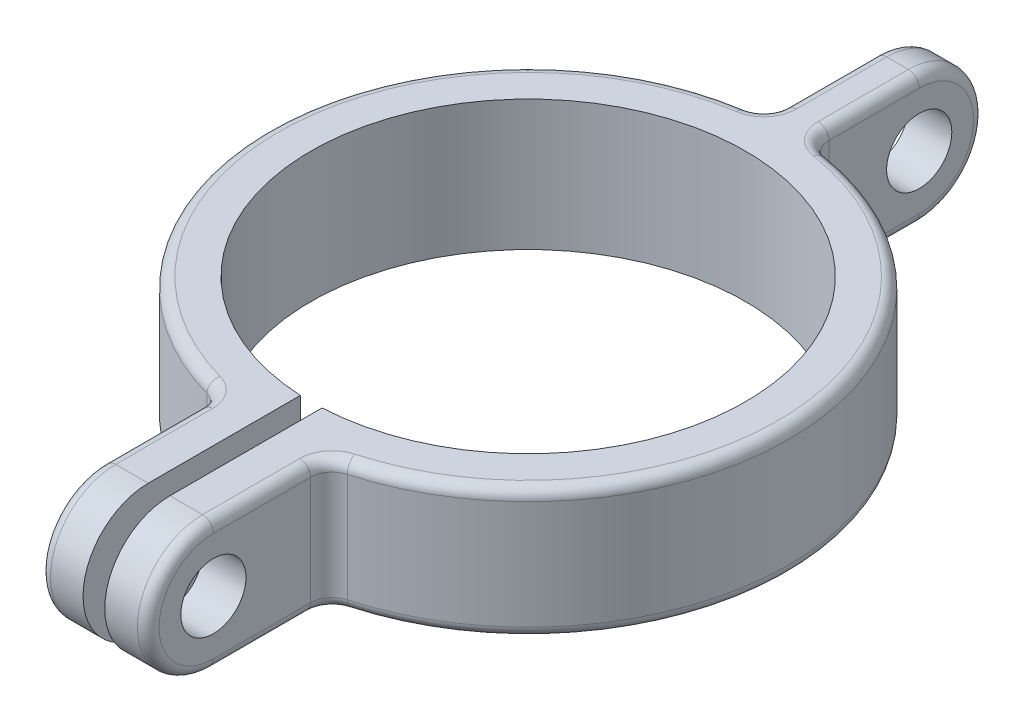
from build123d import *

# Parameters (mm, degrees)
SKETCH1_R          = 38.1
SKETCH1_R_2        = 31.75
EXTRUDE1_DEPTH     = 19.05
SKETCH2_W          = 3.175
SKETCH2_H          = 40.64
CUT_EXTRUDE1_DEPTH = 20.05
EXTRUDE2_DEPTH     = 6.35
SKETCH6_R          = 4.7625
CUT_EXTRUDE3_DEPTH = 47.0375
EXTRUDE4_DEPTH     = 3.175
FILLET4_R          = 3.175
SKETCH10_R         = 4.7625
CUT_EXTRUDE6_DEPTH = 42.275
FILLET5_R          = 1.5875


with BuildPart() as part:
    # Sketch1 → Extrude1 (new body)
    with BuildSketch(Plane(origin=(0, 0, 0), x_dir=(1, 0, 0), z_dir=(0, 1, 0))):
        Circle(SKETCH1_R)
        Circle(SKETCH1_R_2, mode=Mode.SUBTRACT)
    extrude(amount=EXTRUDE1_DEPTH)

    # Sketch2 → Cut-Extrude1 (cut, through all)
    with BuildSketch(Plane(origin=(0, 19.05, 0), x_dir=(-1, 0, 0), z_dir=(0, 1, 0))):
        with Locations((0, 20.32)):
            Rectangle(SKETCH2_W, SKETCH2_H)
    extrude(amount=-CUT_EXTRUDE1_DEPTH, mode=Mode.SUBTRACT)

    # Sketch3 → Extrude2 (add)
    with BuildSketch(Plane.ZY.offset(-1.5875)):
        with BuildLine():
            Line((31.710287664, 19.05), (53.941912716, 19.05))
            ThreePointArc((53.941912716, 19.05), (63.466912716, 9.525), (53.941912716, 0))
            Line((53.941912716, 0), (31.710287664, 0))
            Line((31.710287664, 0), (31.710287664, 19.05))
        make_face()
    extrude2 = extrude(amount=-EXTRUDE2_DEPTH)

    # Mirror1: Extrude2 across plane
    add(extrude2.mirror(Plane(origin=(0, 0, 0), x_dir=(0, 0, 1), z_dir=(1, 0, 0))))

    # Sketch6 → Cut-Extrude3 (cut, through all)
    with BuildSketch(Plane(origin=(7.9375, 0, 0), x_dir=(0, 0, -1), z_dir=(1, 0, 0))):
        with Locations((-53.941912716, 9.525)):
            Circle(SKETCH6_R)
    extrude(amount=-CUT_EXTRUDE3_DEPTH, mode=Mode.SUBTRACT)

    # Sketch7 → Extrude4 (add, symmetric)
    with BuildSketch(Plane(origin=(0, 0, 0), x_dir=(0, 0, -1), z_dir=(1, 0, 0))):
        with BuildLine():
            Line((31.75, 19.05), (53.975, 19.05))
            ThreePointArc((53.975, 19.05), (63.5, 9.525), (53.975, 0))
            Line((53.975, 0), (31.75, 0))
            Line((31.75, 0), (31.75, 19.05))
        make_face()
    extrude(amount=EXTRUDE4_DEPTH, both=True)

    # Fillet4
    fillet4_edges = [part.edges().sort_by_distance(p)[0] for p in [
        (7.9375, 9.525, 37.264005337),
        (-7.9375, 9.525, 37.264005337),
        (-3.175, 9.525, -37.967477859),
        (3.175, 9.525, -37.967477859),
    ]]
    fillet(fillet4_edges, radius=FILLET4_R)

    # Sketch10 → Cut-Extrude6 (cut, through all)
    with BuildSketch(Plane(origin=(3.175, 0, 0), x_dir=(0, 0, -1), z_dir=(1, 0, 0))):
        with Locations((53.975, 9.525)):
            Circle(SKETCH10_R)
    extrude(amount=-CUT_EXTRUDE6_DEPTH, mode=Mode.SUBTRACT)

    # Fillet5
    fillet5_edges = [part.edges().sort_by_distance(p)[0] for p in [
        (-38.033554879, 19.05, -2.249156126),
        (-38.033554879, 0, -2.249156126),
        (-7.9375, 0, 46.846430999),
        (38.033554879, 19.05, -2.249156126),
        (38.033554879, 0, -2.249156126),
        (7.9375, 0, 46.846430999),
        (3.175, 0, -47.379306719),
        (-3.175, 0, -47.379306719),
        (-8.583207666, 19.05, 37.831755365),
        (-8.583207666, 0, 37.831755365),
        (8.583207666, 0, 37.831755365),
        (8.583207666, 19.05, 37.831755365),
        (3.938414382, 0, -38.718454894),
        (3.938414382, 19.05, -38.718454894),
        (-3.938414382, 0, -38.718454894),
        (-3.938414382, 19.05, -38.718454894),
        (7.9375, 19.05, 46.846430999),
        (7.9375, 9.525, 63.466912716),
        (-7.9375, 9.525, 63.466912716),
        (-7.9375, 19.05, 46.846430999),
        (3.175, 19.05, -47.379306719),
        (3.175, 9.525, -63.5),
        (-3.175, 19.05, -47.379306719),
        (-3.175, 9.525, -63.5),
    ]]
    fillet(fillet5_edges, radius=FILLET5_R)


solid = part.part
